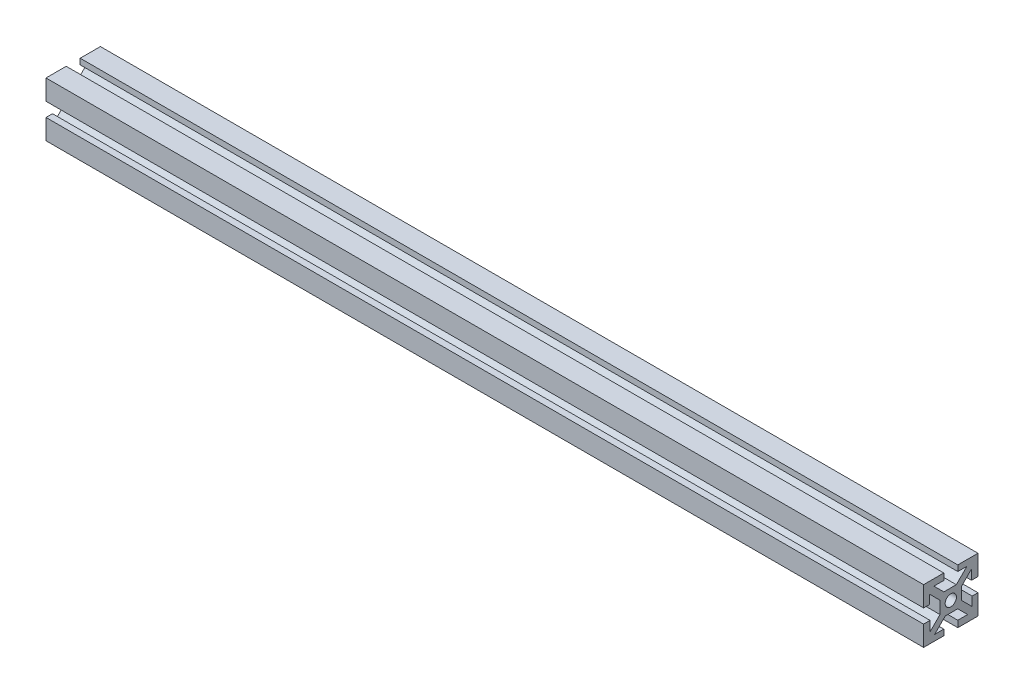
from build123d import *

# Parameters (mm, degrees)
SKETCH1_R           = 2.605
BOSS_EXTRUDE1_DEPTH = 406.4
CIRPATTERN1_COUNT   = 4


with BuildPart() as part:
    # Sketch1 → Boss-Extrude1 (new body)
    with BuildSketch(Plane(origin=(0, 0, 0), x_dir=(0, 0, -1), z_dir=(1, 0, 0))):
        Polygon((5, -5), (5, 3.203948776), (9.596194078, 7.800142853), (9.596194078, 3.24), (12.596194078, 3.24), (12.596194078, 12.596194078), (3.24, 12.596194078), (3.24, 9.921463197), (7.474873734, 9.921463197), (2.553410537, 5), (-5, 5), (-5, -5), align=None)
        Circle(SKETCH1_R, mode=Mode.SUBTRACT)
    boss_extrude1 = extrude(amount=BOSS_EXTRUDE1_DEPTH)

    # CirPattern1: Boss-Extrude1 ×4 about axis
    cirpattern1_axis = Axis((0, 0, 0), (1, 0, 0))
    for i in range(1, CIRPATTERN1_COUNT):
        add(boss_extrude1.rotate(cirpattern1_axis, i * 360 / CIRPATTERN1_COUNT))


solid = part.part
